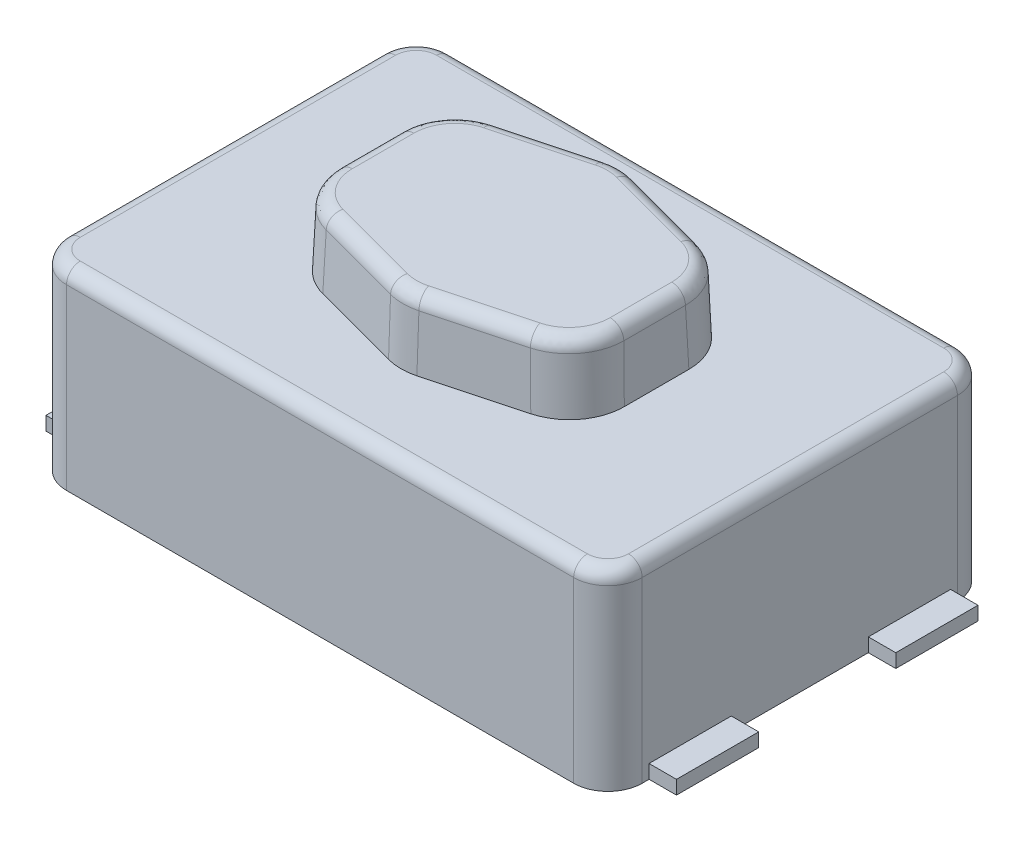
from build123d import *

# Parameters (mm, degrees)
SKETCH1_W               = 4.2
SKETCH1_H               = 2.8
BOSS_EXTRUDE1_DEPTH     = 0.7
BOSS_EXTRUDE2_DEPTH     = 0.5
BOSS_EXTRUDE2_TAPER     = 2
FILLET1_R               = 0.4
FILLET2_R               = 0.1
FILLET3_R               = 0.25
FILLET4_R               = 0.1
SKETCH3_W               = 0.2
SKETCH3_H               = 0.6
BOSS_EXTRUDE3_DEPTH     = 0.1
MIRROR2_COPY_1_SKETCH_W = 0.2
MIRROR2_COPY_1_SKETCH_H = 0.6
MIRROR2_COPY_1_DEPTH    = 0.1


with BuildPart() as part:
    # Sketch1 → Boss-Extrude1 (new body, symmetric)
    with BuildSketch(Plane(origin=(0, 0, 0), x_dir=(1, 0, 0), z_dir=(0, 1, 0))):
        Rectangle(SKETCH1_W, SKETCH1_H)
    extrude(amount=BOSS_EXTRUDE1_DEPTH, both=True)

    # Fillet3
    fillet3_edges = [part.edges().sort_by_distance(p)[0] for p in [
        (2.1, 0, 1.4),
        (-2.1, 0, 1.4),
        (-2.1, 0, -1.4),
        (2.1, 0, -1.4),
    ]]
    fillet(fillet3_edges, radius=FILLET3_R)

    # Fillet4
    fillet4_edges = [part.edges().sort_by_distance(p)[0] for p in [
        (-2.1, 0.7, 0),
        (0, 0.7, -1.4),
        (2.1, 0.7, 0),
        (0, 0.7, 1.4),
        (-2.026776695, 0.7, 1.326776695),
        (2.026776695, 0.7, 1.326776695),
        (2.026776695, 0.7, -1.326776695),
        (-2.026776695, 0.7, -1.326776695),
    ]]
    fillet(fillet4_edges, radius=FILLET4_R)

    # Sketch3 → Boss-Extrude3 (add)
    with BuildSketch(Plane.XZ.offset(0.7)):
        with Locations((-2.2, 0.8)):
            Rectangle(SKETCH3_W, SKETCH3_H)
    boss_extrude3 = extrude(amount=-BOSS_EXTRUDE3_DEPTH)

    # Mirror1: Boss-Extrude3 across plane
    add(boss_extrude3.mirror(Plane.XY))

    # Mirror2: Boss-Extrude3 across plane
    add(boss_extrude3.mirror(Plane(origin=(0, 0, 0), x_dir=(0, 0, 1), z_dir=(1, 0, 0))))

    # Mirror2 copy 1 sketch → Mirror2 copy 1 (add)
    with BuildSketch(Plane(origin=(0, -0.7, 0), x_dir=(-1, 0, 0), z_dir=(0, -1, 0))):
        with Locations((-2.2, 0.8)):
            Rectangle(MIRROR2_COPY_1_SKETCH_W, MIRROR2_COPY_1_SKETCH_H)
    extrude(amount=-MIRROR2_COPY_1_DEPTH)


with BuildPart() as body_2:
    # Sketch2 → Boss-Extrude2 (new body)
    with BuildSketch(Plane(origin=(0, 0.7, 0), x_dir=(1, 0, 0), z_dir=(0, 1, 0))):
        Polygon((-1.055, 0.542313602), (-1.055, -0.542313602), (0, -0.825), (1.055, -0.542313602), (1.055, 0.542313602), (0, 0.825), align=None)
    extrude(amount=BOSS_EXTRUDE2_DEPTH, taper=BOSS_EXTRUDE2_TAPER)

    # Fillet1
    fillet1_edges = [body_2.edges().sort_by_distance(p)[0] for p in [
        (0, 0.95, -0.81596184),
        (1.046269808, 0.95, -0.53561469),
        (1.046269808, 0.95, 0.53561469),
        (0, 0.95, 0.81596184),
        (-1.046269808, 0.95, 0.53561469),
        (-1.046269808, 0.95, -0.53561469),
    ]]
    fillet(fillet1_edges, radius=FILLET1_R)

    # Fillet2
    fillet2_edges = [body_2.edges().sort_by_distance(p)[0] for p in [
        (-1.037539615, 1.2, 0),
        (-0.422356194, 1.2, -0.693753678),
        (-0.422356194, 1.2, 0.693753678),
        (0.422356194, 1.2, 0.693753678),
        (1.037539615, 1.2, 0),
        (0.422356194, 1.2, -0.693753678),
        (-0.95494446, 1.2, 0.46553817),
        (-1e-09, 1.2, 0.792822106),
        (0.954944348, 1.2, 0.465538316),
        (0.95494446, 1.2, -0.46553817),
        (1e-09, 1.2, -0.792822106),
        (-0.95494446, 1.2, -0.46553817),
    ]]
    fillet(fillet2_edges, radius=FILLET2_R)


solid = Compound([part.part, body_2.part])
